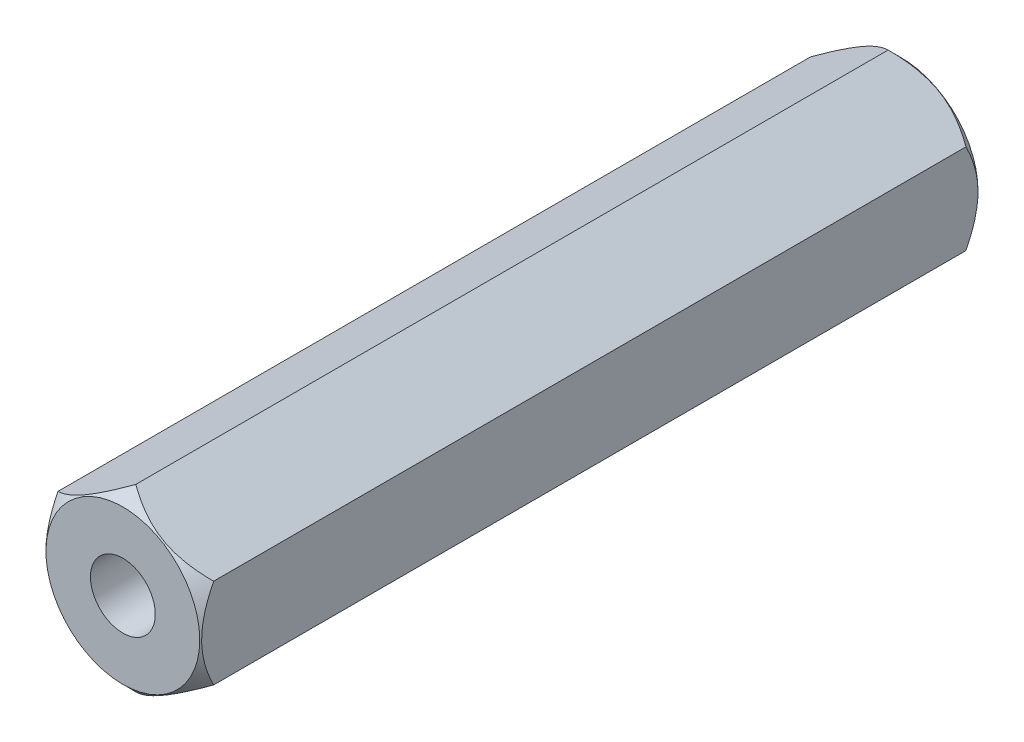
from build123d import *

# Parameters (mm, degrees)
BOSS_EXTRU_1_DEPTH                        = 30
TROU_POUR_TARAUDAGE_POUR_TROU_TARAUD_M3_D = 2.5


with BuildPart() as part:
    # Esquisse1 → Boss.-Extru.1 (new body)
    with BuildSketch(Plane.XY):
        Polygon((0, 3.464101615), (-3, 1.732050808), (-3, -1.732050808), (0, -3.464101615), (3, -1.732050808), (3, 1.732050808), align=None)
    extrude(amount=BOSS_EXTRU_1_DEPTH)

    # Esquisse2 → Enlèvement de matière-Révolution1 (revolve, cut)
    with BuildSketch(Plane(origin=(0, 0, 0), x_dir=(0, 0, -1), z_dir=(1, 0, 0))):
        Polygon((-30, 2.964101615), (-29.5, 3.464101615), (-29.5, 7.964101615), (-34.5, 7.964101615), (-34.5, 2.964101615), align=None)
        Polygon((0, 2.964101615), (4.5, 2.964101615), (4.5, 7.964101615), (-0.5, 7.964101615), (-0.5, 3.464101615), align=None)
    revolve(axis=Axis((0, 0, 1000), (0, 0, -1)), mode=Mode.SUBTRACT)

    # Trou pour taraudage pour trou taraudé M31 (through all)
    with Locations(Plane(origin=(0, 0, 0), x_dir=(-1, 0, 0), z_dir=(0, 0, -1))):
        with Locations((0, 0)):
            Hole(TROU_POUR_TARAUDAGE_POUR_TROU_TARAUD_M3_D / 2)


solid = part.part
